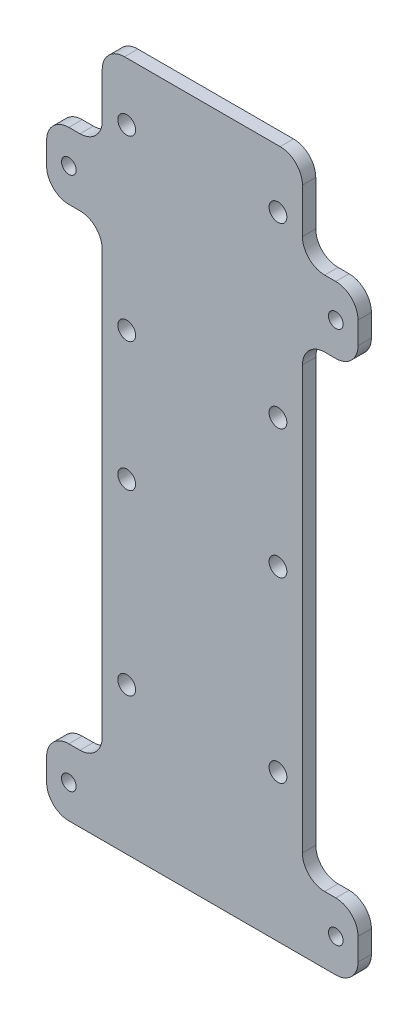
from build123d import *

# Parameters (mm, degrees)
SKETCH_1_W          = 70
SKETCH_1_H          = 155
EXTRUDE_1_DEPTH     = 3
SKETCH_2_R          = 2
SKETCH_2_R_2        = 1.65
CUT_EXTRUDE_1_DEPTH = 3
SKETCH_3_W          = 12.5
SKETCH_3_H          = 105
SKETCH_3_H_2        = 20
CUT_EXTRUDE_2_DEPTH = 10
FILLET_1_R          = 5


with BuildPart() as part:
    # ｽｹｯﾁ1 → ﾎﾞｽ - 押し出し1 (new body)
    with BuildSketch(Plane.XY):
        Rectangle(SKETCH_1_W, SKETCH_1_H)
    extrude(amount=EXTRUDE_1_DEPTH)

    # ｽｹｯﾁ2 → ｶｯﾄ - 押し出し1 (cut)
    with BuildSketch(Plane.XY.offset(3)):
        with Locations((-17, -44.5)):
            Circle(SKETCH_2_R)
        with Locations((17, -44.5)):
            Circle(SKETCH_2_R)
        with Locations((17, -4.5)):
            Circle(SKETCH_2_R)
        with Locations((-17, -4.5)):
            Circle(SKETCH_2_R)
        with Locations((-17, 24.5)):
            Circle(SKETCH_2_R)
        with Locations((-17, 64.5)):
            Circle(SKETCH_2_R)
        with Locations((17, 64.5)):
            Circle(SKETCH_2_R)
        with Locations((17, 24.5)):
            Circle(SKETCH_2_R)
        with Locations((-30, -70)):
            Circle(SKETCH_2_R_2)
        with Locations((30, -70)):
            Circle(SKETCH_2_R_2)
        with Locations((30, 50)):
            Circle(SKETCH_2_R_2)
        with Locations((-30, 50)):
            Circle(SKETCH_2_R_2)
    extrude(amount=-CUT_EXTRUDE_1_DEPTH, mode=Mode.SUBTRACT)

    # ｽｹｯﾁ3 → ｶｯﾄ - 押し出し2 (cut)
    with BuildSketch(Plane.XY.offset(3)):
        with Locations((-28.75, -10)):
            Rectangle(SKETCH_3_W, SKETCH_3_H)
        with Locations((28.75, -10)):
            Rectangle(SKETCH_3_W, SKETCH_3_H)
        with Locations((-28.75, 67.5)):
            Rectangle(SKETCH_3_W, SKETCH_3_H_2)
        with Locations((28.75, 67.5)):
            Rectangle(SKETCH_3_W, SKETCH_3_H_2)
    extrude(amount=-CUT_EXTRUDE_2_DEPTH, mode=Mode.SUBTRACT)

    # ﾌｨﾚｯﾄ1
    fillet_1_edges = [part.edges().sort_by_distance(p)[0] for p in [
        (35, 57.5, 1.5),
        (22.5, 57.5, 1.5),
        (22.5, 77.5, 1.5),
        (35, 42.5, 1.5),
        (35, -62.5, 1.5),
        (22.5, -62.5, 1.5),
        (22.5, 42.5, 1.5),
        (-35, -62.5, 1.5),
        (-35, 42.5, 1.5),
        (-22.5, 42.5, 1.5),
        (-22.5, -62.5, 1.5),
        (-35, -77.5, 1.5),
        (35, -77.5, 1.5),
        (-35, 57.5, 1.5),
        (-22.5, 77.5, 1.5),
        (-22.5, 57.5, 1.5),
    ]]
    fillet(fillet_1_edges, radius=FILLET_1_R)


solid = part.part
